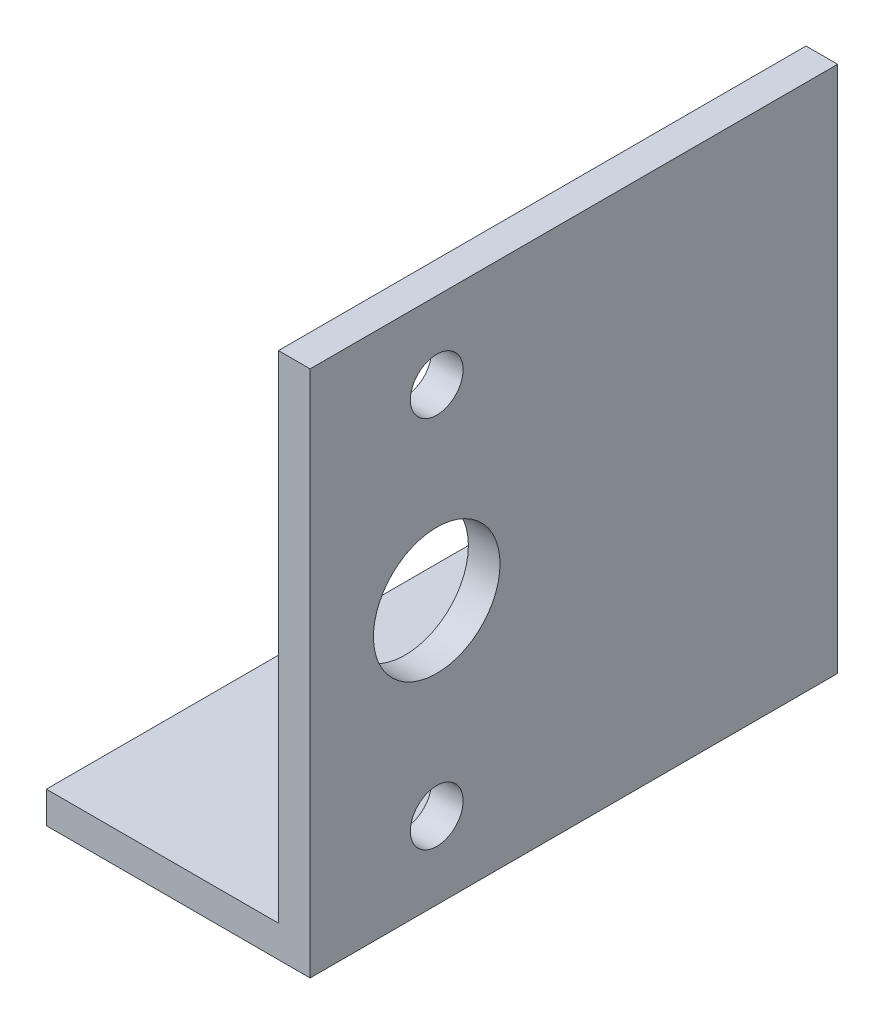
from build123d import *

# Parameters (mm, degrees)
SALIENTE_EXTRUIR1_DEPTH = 50
CROQUIS2_R              = 6
CROQUIS2_R_2            = 2.5
CORTAR_EXTRUIR1_DEPTH   = 3


with BuildPart() as part:
    # Croquis1 → Saliente-Extruir1 (new body)
    with BuildSketch(Plane.XY):
        Polygon((-25, 0), (0, 0), (0, 50), (-3, 50), (-3, 3), (-25, 3), align=None)
    extrude(amount=SALIENTE_EXTRUIR1_DEPTH)

    # Croquis2 → Cortar-Extruir1 (cut)
    with BuildSketch(Plane(origin=(0, 0, 0), x_dir=(0, 0, -1), z_dir=(1, 0, 0))):
        with Locations((-38, 25)):
            Circle(CROQUIS2_R)
        with Locations((-38, 42.7)):
            Circle(CROQUIS2_R_2)
        with Locations((-38, 7.3)):
            Circle(CROQUIS2_R_2)
    extrude(amount=-CORTAR_EXTRUIR1_DEPTH, mode=Mode.SUBTRACT)


solid = part.part
